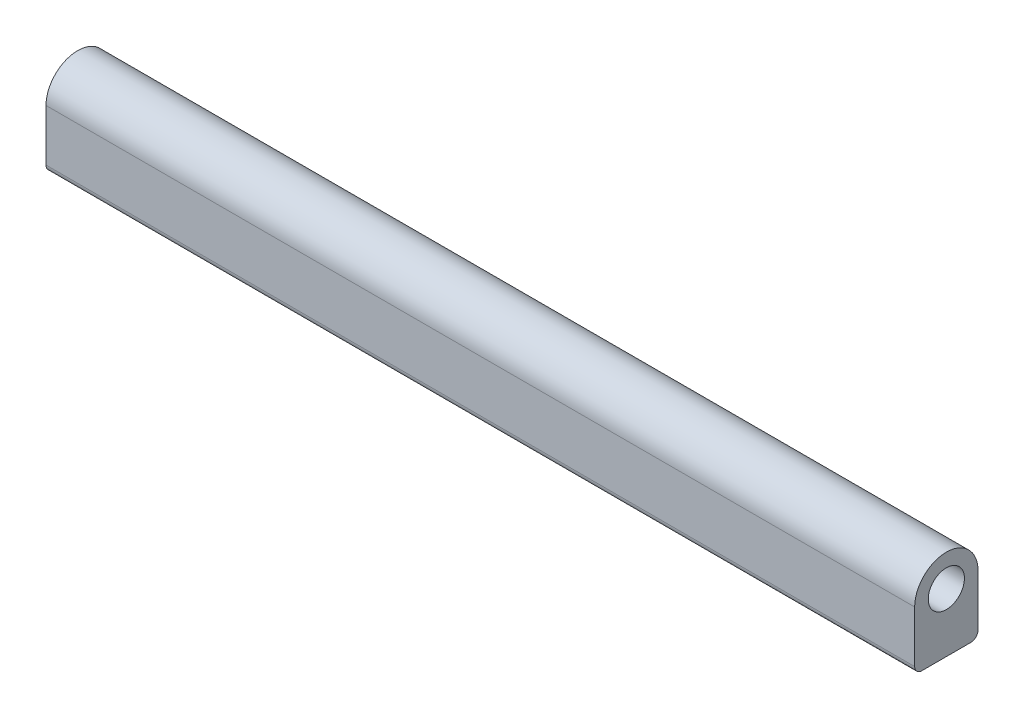
from build123d import *

# Parameters (mm, degrees)
EXTRUDE1_DEPTH                 = 152.4
EXTRUDE1_DEPTH_BACK            = 152.4
SKETCH1_R                      = 6.35
F_13_0_13_DIAMETER_HOLE1_D     = 13
F_13_0_13_DIAMETER_HOLE1_DEPTH = 20.6365
F_13_0_13_DIAMETER_HOLE1_TIP   = 3.905594024


with BuildPart() as part:
    # Sketch1 → Extrude1 (new, two sides: drawn at the far end of the back side and taken through both)
    with BuildSketch(Plane(origin=(0, 0, 0), x_dir=(0, 0, -1), z_dir=(1, 0, 0)).offset(-EXTRUDE1_DEPTH_BACK)):
        with BuildLine():
            Line((-11.1125, 0), (-11.1125, -18.0975))
            ThreePointArc((-11.1125, -18.0975), (-10.368551224, -19.893551224), (-8.5725, -20.6375))
            Line((-8.5725, -20.6375), (8.5725, -20.6375))
            ThreePointArc((8.5725, -20.6375), (10.368551224, -19.893551224), (11.1125, -18.0975))
            Line((11.1125, -18.0975), (11.1125, 0))
            ThreePointArc((11.1125, 0), (0, 11.1125), (-11.1125, 0))
        make_face()
        Circle(SKETCH1_R, mode=Mode.SUBTRACT)
    extrude(amount=EXTRUDE1_DEPTH + EXTRUDE1_DEPTH_BACK)

    # Ø13.0 (13) Diameter Hole1
    with Locations(Plane(origin=(-112.5, -20.6375, 0), x_dir=(0, 0, -1), z_dir=(0, -1, 0))):
        with Locations((0, 0), (0, 75), (0, 150), (0, 225)):
            Hole(F_13_0_13_DIAMETER_HOLE1_D / 2, depth=F_13_0_13_DIAMETER_HOLE1_DEPTH)
            with Locations((0, 0, -(F_13_0_13_DIAMETER_HOLE1_DEPTH + F_13_0_13_DIAMETER_HOLE1_TIP / 2))):  # 118° drill point
                Cone(0, F_13_0_13_DIAMETER_HOLE1_D / 2, F_13_0_13_DIAMETER_HOLE1_TIP, mode=Mode.SUBTRACT)


solid = part.part
